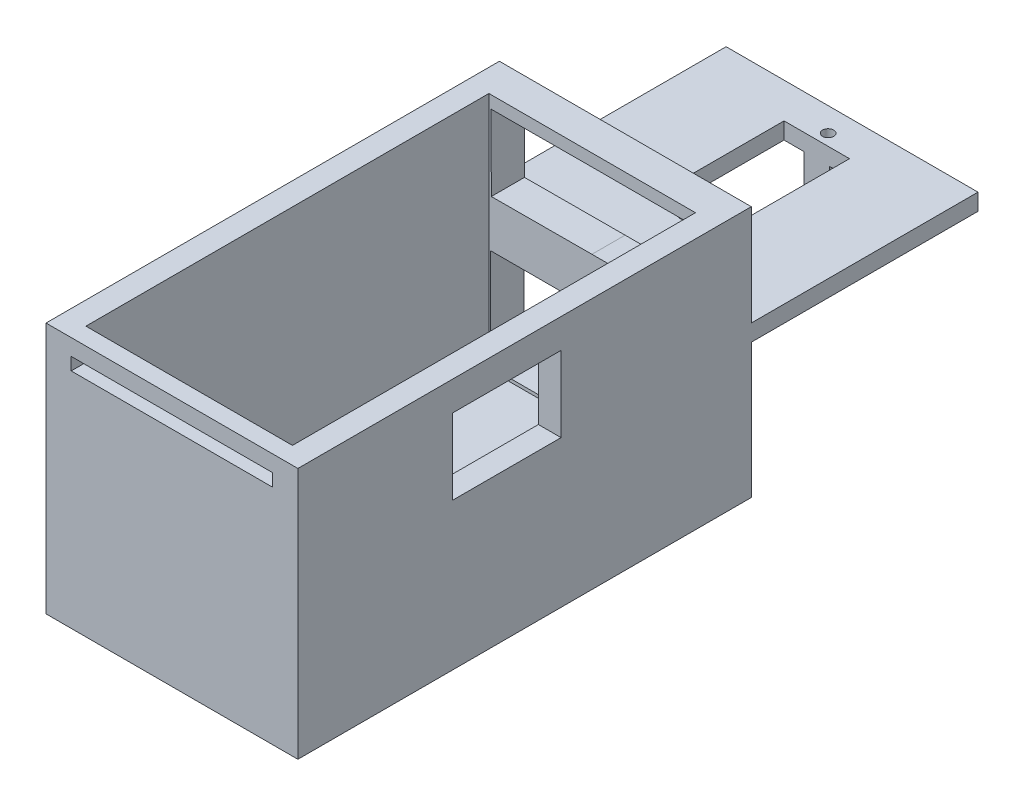
from build123d import *

# Parameters (mm, degrees)
SKETCH_1_W               = 50
SKETCH_1_H               = 50
EXTRUDE_1_DEPTH          = 80
EXTRUDE_1_DEPTH_BACK     = 55
SKETCH_2_W               = 41
SKETCH_2_H               = 80
CUT_EXTRUDE_1_DEPTH      = 47.5
SKETCH_3_W               = 13
SKETCH_3_H               = 23.5
CUT_EXTRUDE_2_DEPTH      = 60
CUT_EXTRUDE_2_DEPTH_BACK = 20
SKETCH_5_W               = 50
SKETCH_5_H               = 45
CUT_EXTRUDE_4_DEPTH      = 20
SKETCH_4_W               = 50
SKETCH_4_H               = 45
CUT_EXTRUDE_5_DEPTH      = 23
CUT_EXTRUDE_5_DEPTH_BACK = 10
CUT_EXTRUDE_6_DEPTH      = 10
SKETCH_7_W               = 40
SKETCH_7_H               = 20
CUT_EXTRUDE_7_DEPTH      = 10
SKETCH_9_W               = 40
SKETCH_9_H               = 2.5
CUT_EXTRUDE_8_DEPTH      = 10
SKETCH_11_W              = 5
SKETCH_11_H              = 4.5
SKETCH_11_H_2            = 5
EXTRUDE_4_DEPTH          = 10
SKETCH_13_W              = 21.5
SKETCH_13_H              = 15
CUT_EXTRUDE_10_DEPTH     = 15
SKETCH_14_R              = 1.1
CUT_EXTRUDE_11_DEPTH     = 12.4


with BuildPart() as part:
    # 草圖1 → 填料-伸長1 (new body, two sides)
    with BuildSketch(Plane.XY) as extrude_1_sk:
        with Locations((-3.62330355, 21.302402801)):
            Rectangle(SKETCH_1_W, SKETCH_1_H)
    extrude(amount=EXTRUDE_1_DEPTH)
    extrude(extrude_1_sk.sketch, amount=-EXTRUDE_1_DEPTH_BACK)

    # 草圖2 → 除料-伸長1 (cut)
    with BuildSketch(Plane(origin=(0, 46.302402801, 0), x_dir=(1, 0, 0), z_dir=(0, 1, 0))):
        with Locations((-3.62330355, -36.580275675)):
            Rectangle(SKETCH_2_W, SKETCH_2_H)
    extrude(amount=-CUT_EXTRUDE_1_DEPTH, mode=Mode.SUBTRACT)

    # 草圖3 → 除料-伸長2 (cut, two sides)
    with BuildSketch(Plane(origin=(0, 0, 0), x_dir=(1, 0, 0), z_dir=(0, 1, 0))) as cut_extrude_2_sk:
        with Locations((-3.62330355, 36.25)):
            Rectangle(SKETCH_3_W, SKETCH_3_H)
    extrude(amount=CUT_EXTRUDE_2_DEPTH, mode=Mode.SUBTRACT)
    extrude(cut_extrude_2_sk.sketch, amount=-CUT_EXTRUDE_2_DEPTH_BACK, mode=Mode.SUBTRACT)

    # 草圖5 → 除料-伸長4 (cut)
    with BuildSketch(Plane(origin=(0, 46.302402801, 0), x_dir=(1, 0, 0), z_dir=(0, 1, 0))):
        with Locations((-3.62330355, 32.5)):
            Rectangle(SKETCH_5_W, SKETCH_5_H)
    extrude(amount=-CUT_EXTRUDE_4_DEPTH, mode=Mode.SUBTRACT)

    # 草圖4 → 除料-伸長5 (cut, two sides)
    with BuildSketch(Plane(origin=(0, 0, 0), x_dir=(1, 0, 0), z_dir=(0, 1, 0))) as cut_extrude_5_sk:
        with Locations((-3.62330355, 32.5)):
            Rectangle(SKETCH_4_W, SKETCH_4_H)
    extrude(amount=CUT_EXTRUDE_5_DEPTH, mode=Mode.SUBTRACT)
    extrude(cut_extrude_5_sk.sketch, amount=-CUT_EXTRUDE_5_DEPTH_BACK, mode=Mode.SUBTRACT)

    # 草圖6 → 除料-伸長6 (cut)
    with BuildSketch(Plane(origin=(0, 0, -10), x_dir=(-1, 0, 0), z_dir=(0, 0, -1))):
        Polygon((3.693842319, 43.884561913), (-16.306157681, 43.884561913), (-16.306157681, 28.884561913), (3.67160538, 28.884561913), (23.649280632, 28.825329472), (23.693754411, 43.825263542), align=None)
    extrude(amount=-CUT_EXTRUDE_6_DEPTH, mode=Mode.SUBTRACT)

    # 草圖7 → 除料-伸長7 (cut)
    with BuildSketch(Plane(origin=(0, 0, -10), x_dir=(-1, 0, 0), z_dir=(0, 0, -1))):
        with Locations((3.768668362, 9.439500409)):
            Rectangle(SKETCH_7_W, SKETCH_7_H)
    extrude(amount=-CUT_EXTRUDE_7_DEPTH, mode=Mode.SUBTRACT)

    # 草圖9 → 除料-伸長8 (cut)
    with BuildSketch(Plane.XY.offset(80)):
        with Locations((-3.62330355, 41.816351076)):
            Rectangle(SKETCH_9_W, SKETCH_9_H)
    extrude(amount=-CUT_EXTRUDE_8_DEPTH, mode=Mode.SUBTRACT)

    # 草圖11 → 填料-伸長4 (add)
    with BuildSketch(Plane(origin=(0, 26.302402801, 0), x_dir=(1, 0, 0), z_dir=(0, 1, 0))):
        with Locations((-3.62330355, 50.25)):
            Rectangle(SKETCH_11_W, SKETCH_11_H)
        with Locations((-3.62330355, 22)):
            Rectangle(SKETCH_11_W, SKETCH_11_H_2)
    extrude(amount=-EXTRUDE_4_DEPTH)

    # 草圖13 → 除料-伸長10 (cut)
    with BuildSketch(Plane(origin=(21.37669645, 0, 0), x_dir=(0, 0, -1), z_dir=(1, 0, 0))):
        with Locations((-38.513161072, 32.983055623)):
            Rectangle(SKETCH_13_W, SKETCH_13_H)
    extrude(amount=-CUT_EXTRUDE_10_DEPTH, mode=Mode.SUBTRACT)

    # 草圖14 → 除料-伸長11 (cut)
    with BuildSketch(Plane(origin=(0, 26.302402801, 0), x_dir=(1, 0, 0), z_dir=(0, 1, 0))):
        with Locations((-3.62330355, 50.25)):
            Circle(SKETCH_14_R)
        with Locations((-3.62330355, 22)):
            Circle(SKETCH_14_R)
    extrude(amount=-CUT_EXTRUDE_11_DEPTH, mode=Mode.SUBTRACT)


solid = part.part
